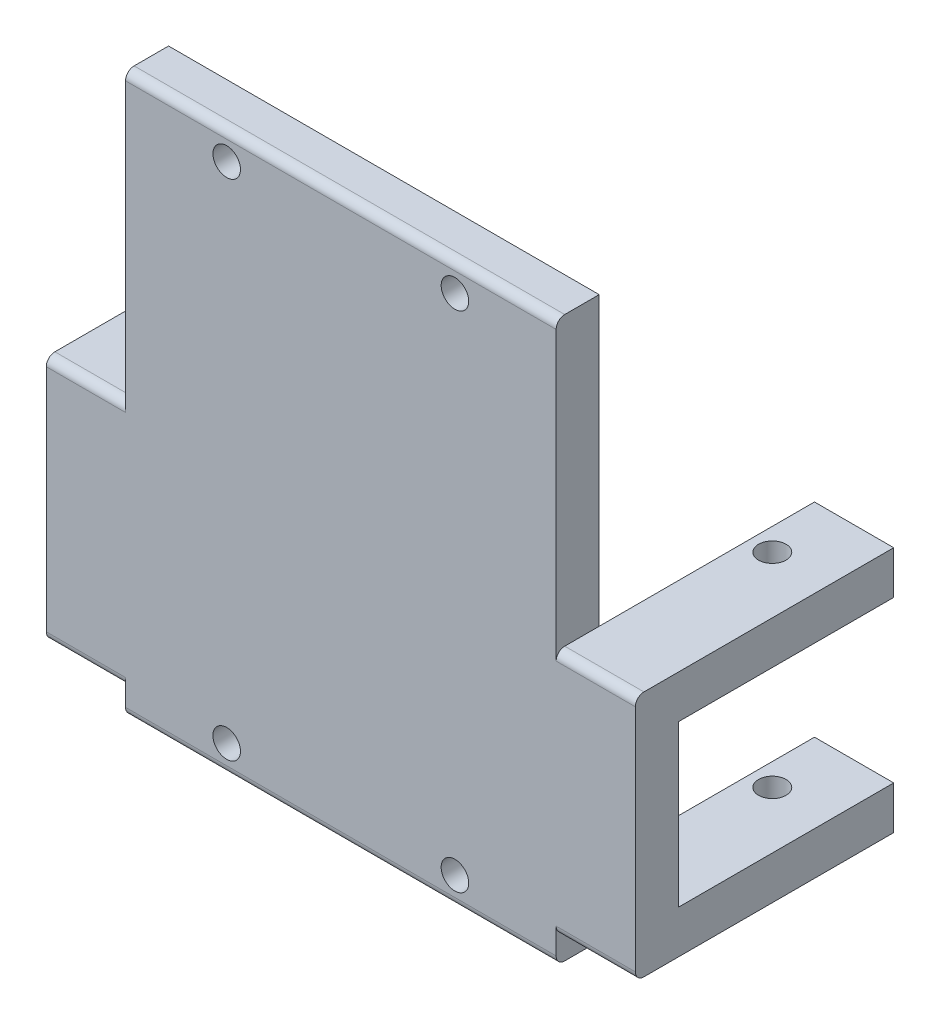
from build123d import *

# Parameters (mm, degrees)
SKETCH2_W                = 50
SKETCH2_H                = 65
SKETCH2_R                = 1.6
SKETCH2_W_2              = 9.2
SKETCH2_H_2              = 5
BOSS_EXTRUDE1_DEPTH      = 5
SKETCH3_W                = 9.2
SKETCH3_H                = 5
BOSS_EXTRUDE2_DEPTH      = 25
BOSS_EXTRUDE2_DEPTH_BACK = 5
SKETCH4_R                = 1.6
CUT_EXTRUDE1_DEPTH       = 32.65
SKETCH5_W                = 9.2
SKETCH5_H                = 18.65
BOSS_EXTRUDE3_DEPTH      = 5
FILLET1_R                = 1


with BuildPart() as part:
    # Sketch2 → Boss-Extrude1 (new body)
    with BuildSketch(Plane.XY):
        Rectangle(SKETCH2_W, SKETCH2_H)
        with Locations((-13.25, -29.25)):
            Circle(SKETCH2_R, mode=Mode.SUBTRACT)
        with Locations((13.25, -29.25)):
            Circle(SKETCH2_R, mode=Mode.SUBTRACT)
        with Locations((13.25, 29.25)):
            Circle(SKETCH2_R, mode=Mode.SUBTRACT)
        with Locations((-13.25, 29.25)):
            Circle(SKETCH2_R, mode=Mode.SUBTRACT)
        with Locations((29.6, -27)):
            Rectangle(SKETCH2_W_2, SKETCH2_H_2)
        with BuildLine():
            Line((25, -29.5), (25, -24.5))
            Line((25, -24.5), (-25, -24.5))
            Line((-25, -24.5), (-25, -29.5))
            Line((-25, -29.5), (-14.830348063, -29.5))
            ThreePointArc((-14.830348063, -29.5), (-13.375385604, -27.65492055), (-11.65, -29.25))
            ThreePointArc((-11.65, -29.25), (-11.65492055, -29.375385604), (-11.669651937, -29.5))
            Line((-11.669651937, -29.5), (11.669651937, -29.5))
            ThreePointArc((11.669651937, -29.5), (13.124614396, -27.65492055), (14.85, -29.25))
            ThreePointArc((14.85, -29.25), (14.84507945, -29.375385604), (14.830348063, -29.5))
            Line((14.830348063, -29.5), (25, -29.5))
        make_face()
        with Locations((-29.6, -27)):
            Rectangle(SKETCH2_W_2, SKETCH2_H_2)
        with BuildLine():
            Line((25, -32.5), (25, -29.5))
            Line((25, -29.5), (14.830348063, -29.5))
            ThreePointArc((14.830348063, -29.5), (13.25, -30.85), (11.669651937, -29.5))
            Line((11.669651937, -29.5), (-11.669651937, -29.5))
            ThreePointArc((-11.669651937, -29.5), (-13.25, -30.85), (-14.830348063, -29.5))
            Line((-14.830348063, -29.5), (-25, -29.5))
            Line((-25, -29.5), (-25, -32.5))
            Line((-25, -32.5), (25, -32.5))
        make_face()
    extrude(amount=BOSS_EXTRUDE1_DEPTH)

    # Sketch3 → Boss-Extrude2 (add, two sides)
    with BuildSketch(Plane(origin=(0, 0, 0), x_dir=(-1, 0, 0), z_dir=(0, 0, -1))) as boss_extrude2_sk:
        with Locations((-29.6, -27)):
            Rectangle(SKETCH3_W, SKETCH3_H)
        with Locations((-29.6, -3.35)):
            Rectangle(SKETCH3_W, SKETCH3_H)
        with Locations((29.6, -27)):
            Rectangle(SKETCH3_W, SKETCH3_H)
        with Locations((29.6, -3.35)):
            Rectangle(SKETCH3_W, SKETCH3_H)
    extrude(amount=BOSS_EXTRUDE2_DEPTH)
    extrude(boss_extrude2_sk.sketch, amount=-BOSS_EXTRUDE2_DEPTH_BACK)

    # Sketch4 → Cut-Extrude1 (cut, through all)
    with BuildSketch(Plane(origin=(0, -0.85, 0), x_dir=(1, 0, 0), z_dir=(0, 1, 0))):
        with Locations((27.6, 17.5)):
            Circle(SKETCH4_R)
        with Locations((-27.6, 17.5)):
            Circle(SKETCH4_R)
    extrude(amount=-CUT_EXTRUDE1_DEPTH, mode=Mode.SUBTRACT)

    # Sketch5 → Boss-Extrude3 (add)
    with BuildSketch(Plane.XY.offset(5)):
        with Locations((-29.6, -15.175)):
            Rectangle(SKETCH5_W, SKETCH5_H)
        with Locations((29.6, -15.175)):
            Rectangle(SKETCH5_W, SKETCH5_H)
    extrude(amount=-BOSS_EXTRUDE3_DEPTH)

    # Fillet1
    fillet1_edges = [part.edges().sort_by_distance(p)[0] for p in [
        (-29.6, -29.5, 5),
        (0, -32.5, 5),
        (29.6, -29.5, 5),
        (0, 32.5, 5),
        (-29.6, -0.85, 5),
        (29.6, -0.85, 5),
    ]]
    fillet(fillet1_edges, radius=FILLET1_R)


solid = part.part
